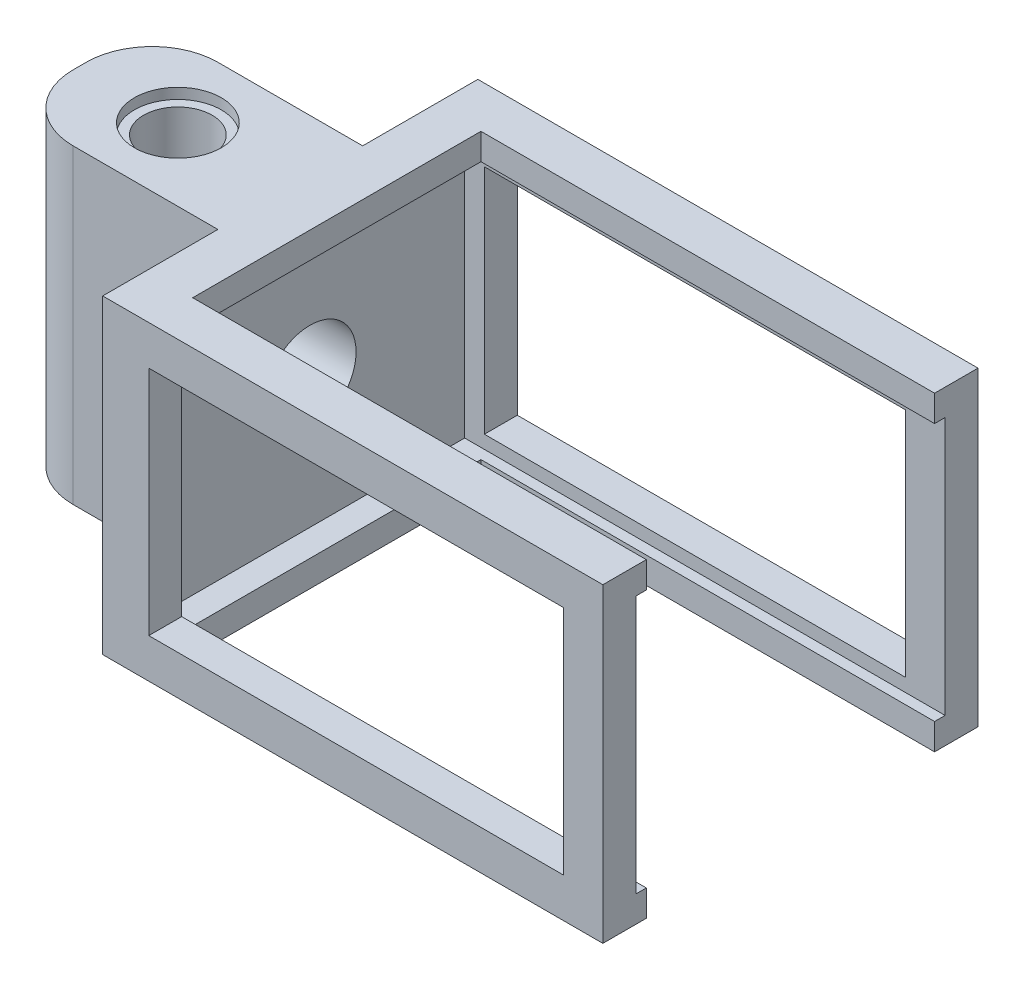
from build123d import *

# Parameters (mm, degrees)
SKETCH2_W            = 38
SKETCH2_H            = 23.6
BOSS_EXTRUDE2_DEPTH  = 2.5
SKETCH3_W            = 35
SKETCH3_H            = 17.6
CUT_EXTRUDE2_DEPTH   = 2.5
SKETCH5_W            = 36.5
SKETCH5_H            = 2
SKETCH5_W_2          = 1.5
SKETCH5_H_2          = 19.6
BOSS_EXTRUDE3_DEPTH  = 26
SKETCH7_W            = 36.5
SKETCH7_H            = 2.5
BOSS_EXTRUDE5_DEPTH  = 1
SKETCH10_W           = 12.597499818
SKETCH10_H           = 2.5
SKETCH10_W_2         = 23.902500182
BOSS_EXTRUDE6_DEPTH  = 1
SKETCH11_W           = 2.5
SKETCH11_H           = 17.6
BOSS_EXTRUDE7_DEPTH  = 2
SKETCH15_W           = 30.589508609
SKETCH15_H           = 23.5
SKETCH15_W_2         = 3.8732763
CUT_EXTRUDE4_DEPTH   = 30
SKETCH16_W           = 3
SKETCH16_H           = 2.5
BOSS_EXTRUDE8_DEPTH  = 20
SKETCH17_W           = 3
SKETCH17_H           = 2.5
BOSS_EXTRUDE9_DEPTH  = 20
SKETCH19_W           = 5.5
SKETCH19_H           = 23.6
BOSS_EXTRUDE10_DEPTH = 16
SKETCH20_R           = 2.6
CUT_EXTRUDE6_DEPTH   = 30
SKETCH21_R           = 3.3
CUT_EXTRUDE7_DEPTH   = 0.8
SKETCH22_R           = 3.3
CUT_EXTRUDE8_DEPTH   = 0.8
FILLET1_R            = 5
FILLET3_R            = 5
SKETCH23_W           = 34.462784909
SKETCH23_H           = 2
BOSS_EXTRUDE11_DEPTH = 0.8
SKETCH24_W           = 34.462784909
SKETCH24_H           = 2
BOSS_EXTRUDE12_DEPTH = 0.8
SKETCH25_W           = 34.462784909
SKETCH25_H           = 2
BOSS_EXTRUDE13_DEPTH = 0.8
SKETCH26_W           = 34.462784909
SKETCH26_H           = 2
BOSS_EXTRUDE14_DEPTH = 0.8
CUT_EXTRUDE9_DEPTH   = 6


with BuildPart() as part:
    # Sketch2 → Boss-Extrude2 (new body)
    with BuildSketch(Plane.XY):
        with Locations((19, 11.8)):
            Rectangle(SKETCH2_W, SKETCH2_H)
    extrude(amount=BOSS_EXTRUDE2_DEPTH)

    # Sketch3 → Cut-Extrude2 (cut)
    with BuildSketch(Plane.XY.offset(2.5)):
        with Locations((20.5, 11.8)):
            Rectangle(SKETCH3_W, SKETCH3_H)
    extrude(amount=-CUT_EXTRUDE2_DEPTH, mode=Mode.SUBTRACT)

    # Sketch5 → Boss-Extrude3 (add)
    with BuildSketch(Plane.XY.offset(2.5)):
        with Locations((19.75, 22.6)):
            Rectangle(SKETCH5_W, SKETCH5_H)
        with Locations((0.75, 22.6)):
            Rectangle(SKETCH5_W_2, SKETCH5_H)
        with Locations((0.75, 11.8)):
            Rectangle(SKETCH5_W_2, SKETCH5_H_2)
        with Locations((0.75, 1)):
            Rectangle(SKETCH5_W_2, SKETCH5_H)
        with Locations((19.75, 1)):
            Rectangle(SKETCH5_W, SKETCH5_H)
    extrude(amount=BOSS_EXTRUDE3_DEPTH)

    # Sketch7 → Boss-Extrude5 (add)
    with BuildSketch(Plane(origin=(0, 2, 0), x_dir=(1, 0, 0), z_dir=(0, 1, 0))):
        with Locations((19.75, -27.25)):
            Rectangle(SKETCH7_W, SKETCH7_H)
    extrude(amount=BOSS_EXTRUDE5_DEPTH)

    # Sketch10 → Boss-Extrude6 (add)
    with BuildSketch(Plane.XZ.offset(-21.6)):
        with Locations((31.701250091, 27.25)):
            Rectangle(SKETCH10_W, SKETCH10_H)
        with Locations((13.451250091, 27.25)):
            Rectangle(SKETCH10_W_2, SKETCH10_H)
    extrude(amount=BOSS_EXTRUDE6_DEPTH)

    # Sketch11 → Boss-Extrude7 (add)
    with BuildSketch(Plane(origin=(1.5, 0, 0), x_dir=(0, 0, -1), z_dir=(1, 0, 0))):
        with Locations((-27.25, 11.8)):
            Rectangle(SKETCH11_W, SKETCH11_H)
    extrude(amount=BOSS_EXTRUDE7_DEPTH)

    # Sketch15 → Cut-Extrude4 (cut)
    with BuildSketch(Plane(origin=(0, 23.6, 0), x_dir=(1, 0, 0), z_dir=(0, 1, 0))):
        with Locations((18.831969395, -14.25)):
            Rectangle(SKETCH15_W, SKETCH15_H)
        with Locations((36.06336185, -14.25)):
            Rectangle(SKETCH15_W_2, SKETCH15_H)
    extrude(amount=-CUT_EXTRUDE4_DEPTH, mode=Mode.SUBTRACT)

    # Sketch16 → Boss-Extrude8 (add)
    with BuildSketch(Plane(origin=(0, 3, 0), x_dir=(1, 0, 0), z_dir=(0, 1, 0))):
        with Locations((36.5, -1.25)):
            Rectangle(SKETCH16_W, SKETCH16_H)
    extrude(amount=BOSS_EXTRUDE8_DEPTH)

    # Sketch17 → Boss-Extrude9 (add)
    with BuildSketch(Plane(origin=(0, 3, 0), x_dir=(1, 0, 0), z_dir=(0, 1, 0))):
        with Locations((36.5, -27.25)):
            Rectangle(SKETCH17_W, SKETCH17_H)
    extrude(amount=BOSS_EXTRUDE9_DEPTH)

    # Sketch19 → Boss-Extrude10 (add)
    with BuildSketch(Plane.ZY):
        with Locations((17, 11.8)):
            Rectangle(SKETCH19_W, SKETCH19_H)
        with Locations((11.5, 11.8)):
            Rectangle(SKETCH19_W, SKETCH19_H)
    extrude(amount=BOSS_EXTRUDE10_DEPTH)

    # Sketch20 → Cut-Extrude6 (cut)
    with BuildSketch(Plane(origin=(0, 23.6, 0), x_dir=(1, 0, 0), z_dir=(0, 1, 0))):
        with Locations((-8.54, -14.25)):
            Circle(SKETCH20_R)
    extrude(amount=-CUT_EXTRUDE6_DEPTH, mode=Mode.SUBTRACT)

    # Sketch21 → Cut-Extrude7 (cut)
    with BuildSketch(Plane(origin=(0, 23.6, 0), x_dir=(1, 0, 0), z_dir=(0, 1, 0))):
        with Locations((-8.54, -14.25)):
            Circle(SKETCH21_R)
    extrude(amount=-CUT_EXTRUDE7_DEPTH, mode=Mode.SUBTRACT)

    # Sketch22 → Cut-Extrude8 (cut)
    with BuildSketch(Plane.XZ):
        with Locations((-8.54, 14.25)):
            Circle(SKETCH22_R)
    extrude(amount=-CUT_EXTRUDE8_DEPTH, mode=Mode.SUBTRACT)

    # Fillet1
    fillet1_edges = [part.edges().sort_by_distance(p)[0] for p in [
        (-16, 11.8, 8.75),
    ]]
    fillet(fillet1_edges, radius=FILLET1_R)

    # Fillet3
    fillet3_edges = [part.edges().sort_by_distance(p)[0] for p in [
        (-16, 11.8, 19.75),
    ]]
    fillet(fillet3_edges, radius=FILLET3_R)

    # Sketch23 → Boss-Extrude11 (add)
    with BuildSketch(Plane(origin=(0, 0, 26), x_dir=(-1, 0, 0), z_dir=(0, 0, -1))):
        with Locations((-20.768607546, 22.6)):
            Rectangle(SKETCH23_W, SKETCH23_H)
    extrude(amount=BOSS_EXTRUDE11_DEPTH)

    # Sketch24 → Boss-Extrude12 (add)
    with BuildSketch(Plane.XY.offset(2.5)):
        with Locations((20.768607546, 22.6)):
            Rectangle(SKETCH24_W, SKETCH24_H)
    extrude(amount=BOSS_EXTRUDE12_DEPTH)

    # Sketch25 → Boss-Extrude13 (add)
    with BuildSketch(Plane(origin=(0, 0, 26), x_dir=(-1, 0, 0), z_dir=(0, 0, -1))):
        with Locations((-20.768607546, 1)):
            Rectangle(SKETCH25_W, SKETCH25_H)
    extrude(amount=BOSS_EXTRUDE13_DEPTH)

    # Sketch26 → Boss-Extrude14 (add)
    with BuildSketch(Plane.XY.offset(2.5)):
        with Locations((20.768607546, 1)):
            Rectangle(SKETCH26_W, SKETCH26_H)
    extrude(amount=BOSS_EXTRUDE14_DEPTH)

    # Sketch27 → Cut-Extrude9 (cut)
    with BuildSketch(Plane(origin=(1.5, 0, 0), x_dir=(0, 0, -1), z_dir=(1, 0, 0))):
        with BuildLine():
            ThreePointArc((-17.75, 11.8), (-16.724873734, 9.325126266), (-14.25, 8.3))
            Line((-14.25, 8.3), (-14.25, 11.8))
            Line((-14.25, 11.8), (-17.75, 11.8))
        make_face()
        with BuildLine():
            Line((-14.25, 11.8), (-14.25, 8.3))
            ThreePointArc((-14.25, 8.3), (-11.775126266, 9.325126266), (-10.75, 11.8))
            Line((-10.75, 11.8), (-14.25, 11.8))
        make_face()
        with BuildLine():
            Line((-17.75, 11.8), (-14.25, 11.8))
            Line((-14.25, 11.8), (-14.25, 15.3))
            ThreePointArc((-14.25, 15.3), (-16.724873734, 14.274873734), (-17.75, 11.8))
        make_face()
        with BuildLine():
            Line((-14.25, 15.3), (-14.25, 11.8))
            Line((-14.25, 11.8), (-10.75, 11.8))
            ThreePointArc((-10.75, 11.8), (-11.775126266, 14.274873734), (-14.25, 15.3))
        make_face()
    extrude(amount=-CUT_EXTRUDE9_DEPTH, mode=Mode.SUBTRACT)


solid = part.part
